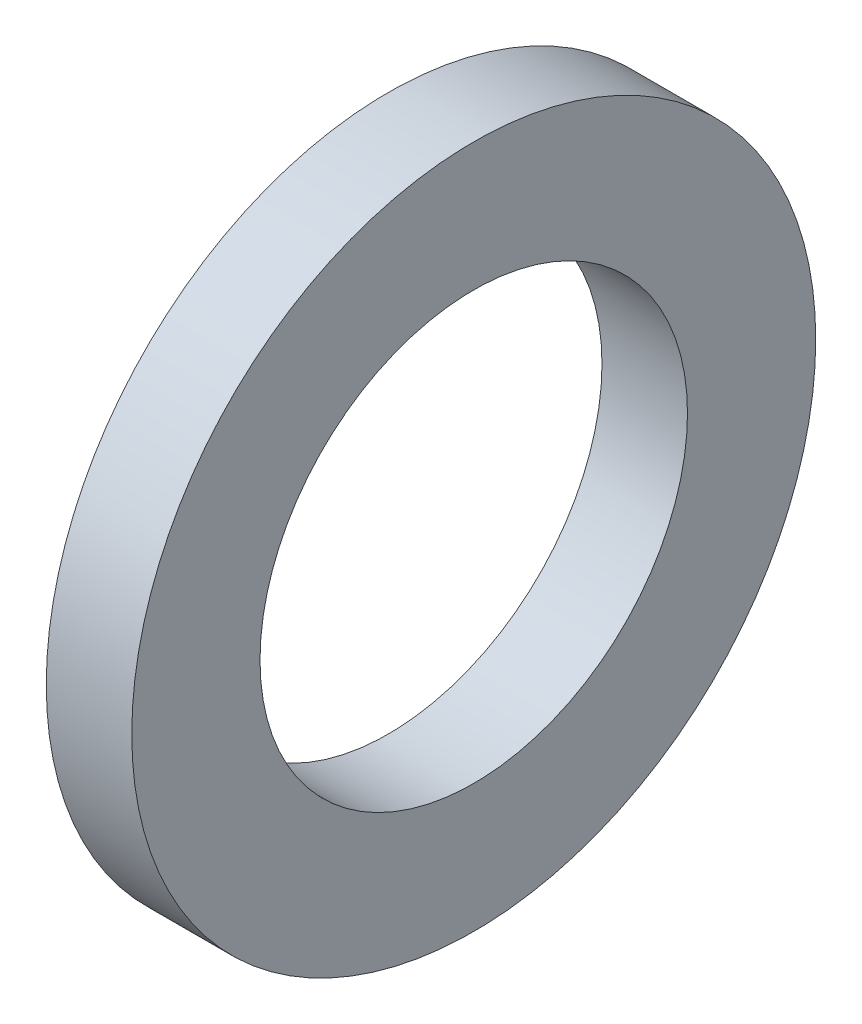
from build123d import *

# Parameters (mm, degrees)
SKETCH1_R           = 4
SKETCH1_R_2         = 2.5
BOSS_EXTRUDE1_DEPTH = 1


with BuildPart() as part:
    # Sketch1 → Boss-Extrude1 (new body)
    with BuildSketch(Plane(origin=(0, 0, 0), x_dir=(0, 0, -1), z_dir=(1, 0, 0))):
        Circle(SKETCH1_R)
        Circle(SKETCH1_R_2, mode=Mode.SUBTRACT)
    extrude(amount=BOSS_EXTRUDE1_DEPTH)


solid = part.part
